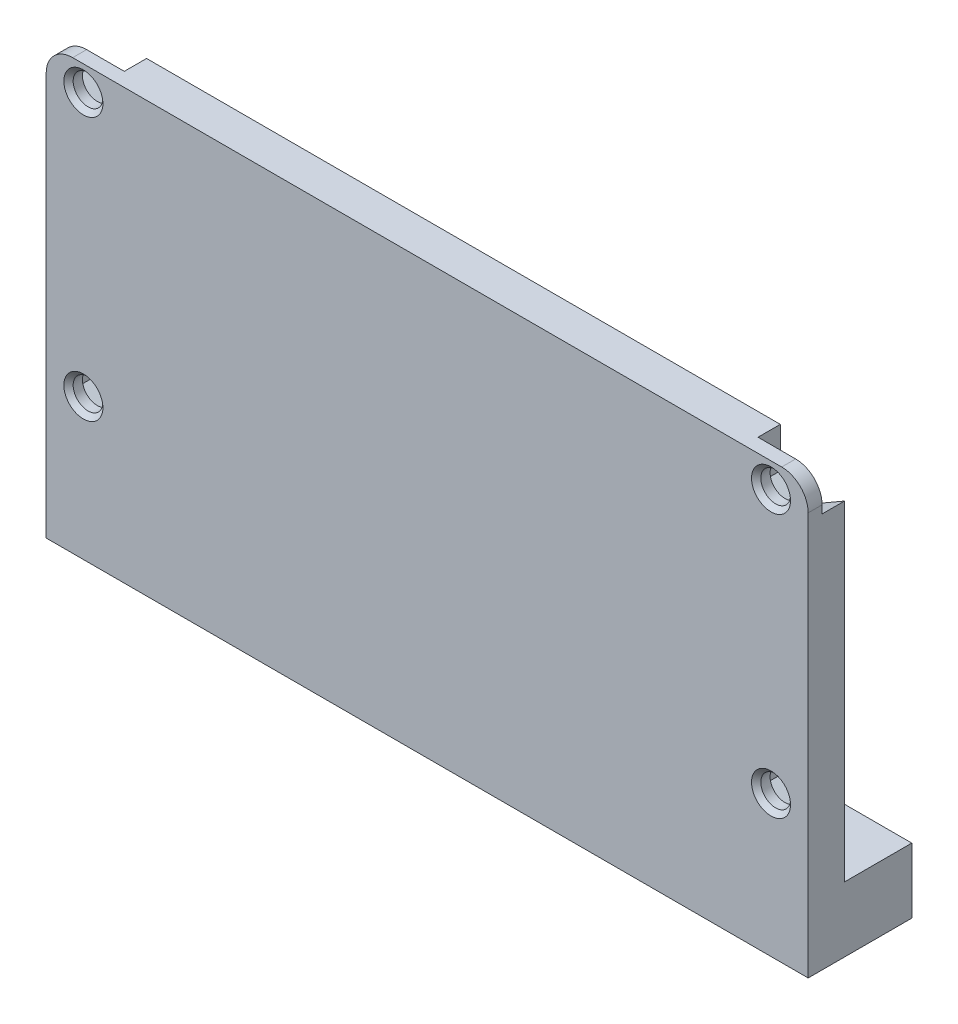
from build123d import *

# Parameters (mm, degrees)
SKETCH1_R                = 1.6
BOSS_EXTRUDE1_DEPTH      = 11.15
SKETCH2_W                = 82
SKETCH2_H                = 0.6
CUT_EXTRUDE1_DEPTH       = 8
CUT_EXTRUDE2_DEPTH       = 46.2
CUT_EXTRUDE3_DEPTH       = 40.2
CUT_EXTRUDE5_DEPTH       = 39.2
BOSS_EXTRUDE2_DEPTH      = 32.2
CHAMFER3_SIZE            = 1.1
CHAMFER4_SIZE            = 1.1
CUT_EXTRUDE12_DEPTH      = 1
CUT_EXTRUDE12_DEPTH_BACK = 83
FILLET3_R                = 15
SKETCH14_R               = 1.6
CUT_EXTRUDE14_DEPTH      = 12.1500001
BOSS_EXTRUDE3_DEPTH      = 3.5
SKETCH8_W                = 82
SKETCH8_H                = 0.6
CUT_EXTRUDE16_DEPTH      = 4.15
CUT_EXTRUDE17_DEPTH      = 2.4
CHAMFER5_SIZE            = 0.5


with BuildPart() as part:
    # Sketch1 → Boss-Extrude1 (new body)
    with BuildSketch(Plane.XY):
        with BuildLine():
            Line((0, -35.2), (82, -35.2))
            Line((82, -35.2), (82, 8.75))
            ThreePointArc((82, 8.75), (81.165254326, 10.765254326), (79.15, 11.6))
            Line((79.15, 11.6), (2.85, 11.6))
            ThreePointArc((2.85, 11.6), (0.834745674, 10.765254326), (0, 8.75))
            Line((0, 8.75), (0, -35.2))
        make_face()
        with Locations((4, 8.939640599)):
            Circle(SKETCH1_R, mode=Mode.SUBTRACT)
        with Locations((78, 8.939640599)):
            Circle(SKETCH1_R, mode=Mode.SUBTRACT)
    extrude(amount=BOSS_EXTRUDE1_DEPTH)

    # Sketch2 → Cut-Extrude1 (cut)
    with BuildSketch(Plane(origin=(0, 0, 0), x_dir=(-1, 0, 0), z_dir=(0, 0, -1))):
        with Locations((-41, -34.9)):
            Rectangle(SKETCH2_W, SKETCH2_H)
    cut_extrude1 = extrude(amount=-CUT_EXTRUDE1_DEPTH, mode=Mode.SUBTRACT)

    # Sketch3 → Cut-Extrude2 (cut)
    with BuildSketch(Plane.XZ.offset(34.6)):
        with BuildLine():
            Line((25.85, 4), (25.85, 0))
            Line((25.85, 0), (29.15, 0))
            Line((29.15, 0), (29.15, 4))
            ThreePointArc((29.15, 4), (27.5, 5.65), (25.85, 4))
        make_face()
        with BuildLine():
            ThreePointArc((14.15, 4), (12.5, 5.65), (10.85, 4))
            Line((10.85, 4), (10.85, 0))
            Line((10.85, 0), (14.15, 0))
            Line((14.15, 0), (14.15, 4))
        make_face()
        with BuildLine():
            ThreePointArc((23.25, 4), (20, 7.25), (16.75, 4))
            Line((16.75, 4), (16.75, 0))
            Line((16.75, 0), (23.25, 0))
            Line((23.25, 0), (23.25, 4))
        make_face()
    cut_extrude2 = extrude(amount=-CUT_EXTRUDE2_DEPTH, mode=Mode.SUBTRACT)

    # Sketch4 → Cut-Extrude3 (cut)
    with BuildSketch(Plane(origin=(0, 11.6, 0), x_dir=(1, 0, 0), z_dir=(0, 1, 0))):
        with BuildLine():
            Line((9.25, -4), (9.25, 0))
            Line((9.25, 0), (15.75, 0))
            Line((15.75, 0), (15.75, -4))
            ThreePointArc((15.75, -4), (12.5, -7.25), (9.25, -4))
        make_face()
        with BuildLine():
            Line((24.25, -4), (24.25, 0))
            Line((24.25, 0), (30.75, 0))
            Line((30.75, 0), (30.75, -4))
            ThreePointArc((30.75, -4), (27.5, -7.25), (24.25, -4))
        make_face()
    cut_extrude3 = extrude(amount=-CUT_EXTRUDE3_DEPTH, mode=Mode.SUBTRACT)

    # Sketch6 → Cut-Extrude5 (cut)
    with BuildSketch(Plane(origin=(0, 11.6, 0), x_dir=(1, 0, 0), z_dir=(0, 1, 0))):
        with BuildLine():
            Line((15.75, -4), (15.75, 0))
            Line((15.75, 0), (15.75, 0.65176216))
            Line((15.75, 0.65176216), (0, 0.65176216))
            Line((0, 0.65176216), (0, -7.25))
            Line((0, -7.25), (12.5, -7.25))
            ThreePointArc((12.5, -7.25), (14.798097039, -6.298097039), (15.75, -4))
        make_face()
        with BuildLine():
            Line((24.25, 0), (24.25, -4))
            ThreePointArc((24.25, -4), (25.201902961, -6.298097039), (27.5, -7.25))
            Line((27.5, -7.25), (41, -7.25))
            Line((41, -7.25), (41, 0))
            Line((41, 0), (24.25, 0))
        make_face()
    cut_extrude5 = extrude(amount=-CUT_EXTRUDE5_DEPTH, mode=Mode.SUBTRACT)

    # Mirror1: Cut-Extrude1, Cut-Extrude2, Cut-Extrude3, Cut-Extrude5 across plane
    add(cut_extrude1.mirror(Plane.ZY.offset(-41)), mode=Mode.SUBTRACT)
    add(cut_extrude2.mirror(Plane.ZY.offset(-41)), mode=Mode.SUBTRACT)
    add(cut_extrude3.mirror(Plane.ZY.offset(-41)), mode=Mode.SUBTRACT)
    add(cut_extrude5.mirror(Plane.ZY.offset(-41)), mode=Mode.SUBTRACT)

    # Sketch12 → Boss-Extrude2 (add)
    with BuildSketch(Plane(origin=(0, 11.6, 0), x_dir=(1, 0, 0), z_dir=(0, 1, 0))):
        with BuildLine():
            Line((16.75, -4), (16.75, 0))
            Line((16.75, 0), (18, 0))
            Line((18, 0), (18.11, -3.084631222))
            ThreePointArc((18.11, -3.084631222), (20, -6.1), (21.89, -3.084631222))
            Line((21.89, -3.084631222), (22, 0))
            Line((22, 0), (23.25, 0))
            Line((23.25, 0), (23.25, -4))
            ThreePointArc((23.25, -4), (20, -7.25), (16.75, -4))
        make_face()
        with BuildLine():
            Line((58.75, -4), (58.75, 0))
            Line((58.75, 0), (60.05, 0))
            Line((60.05, 0), (60.155, -3.106425717))
            ThreePointArc((60.155, -3.106425717), (62, -6.05), (63.845, -3.106425717))
            Line((63.845, -3.106425717), (63.95, 0))
            Line((63.95, 0), (65.25, 0))
            Line((65.25, 0), (65.25, -4))
            ThreePointArc((65.25, -4), (62, -7.25), (58.75, -4))
        make_face()
    extrude(amount=-BOSS_EXTRUDE2_DEPTH)

    # Chamfer3
    chamfer3_edges = [part.edges().sort_by_distance(p)[0] for p in [
        (65.25, -20.6, 2),
        (58.75, -20.6, 2),
        (62, -20.6, 7.25),
    ]]
    chamfer(chamfer3_edges, length=CHAMFER3_SIZE)

    # Chamfer4
    chamfer4_edges = [part.edges().sort_by_distance(p)[0] for p in [
        (23.25, -20.6, 2),
        (16.75, -20.6, 2),
        (20, -20.6, 7.25),
    ]]
    chamfer(chamfer4_edges, length=CHAMFER4_SIZE)

    # Sketch9 → Cut-Extrude12 (cut, two sides)
    with BuildSketch(Plane.ZY) as cut_extrude12_sk:
        Polygon((-106.219800457, 11.6), (0, 11.6), (7.25, 11.6), (0, 2.4), (-65.744961499, -81.028089075), (-260.411588221, -166.089763625), (-300.886427179, -73.46167455), align=None)
    extrude(amount=CUT_EXTRUDE12_DEPTH, mode=Mode.SUBTRACT)
    extrude(cut_extrude12_sk.sketch, amount=-CUT_EXTRUDE12_DEPTH_BACK, mode=Mode.SUBTRACT)

    # Fillet3
    fillet3_edges = [part.edges().sort_by_distance(p)[0] for p in [
        (16.875, 2.4, 0),
        (23.125, 2.4, 0),
        (58.9, 2.4, 0),
        (65.1, 2.4, 0),
    ]]
    fillet(fillet3_edges, radius=FILLET3_R)

    # Sketch14 → Cut-Extrude14 (cut, through all)
    with BuildSketch(Plane.XY.offset(11.15)):
        with Locations((4, -19.400359401)):
            Circle(SKETCH14_R)
    cut_extrude14 = extrude(amount=-CUT_EXTRUDE14_DEPTH, mode=Mode.SUBTRACT)

    # Mirror3: Cut-Extrude14 across plane
    add(cut_extrude14.mirror(Plane.ZY.offset(-41)), mode=Mode.SUBTRACT)

    # Sketch18 → Boss-Extrude3 (add)
    with BuildSketch(Plane(origin=(0, -27.6, 0), x_dir=(1, 0, 0), z_dir=(0, 1, 0))):
        with BuildLine():
            Line((14.15, 0), (14.15, -1.2))
            ThreePointArc((14.15, -1.2), (15.321790212, -2.38754845), (15.75, -4))
            Line((15.75, -4), (15.75, 0))
            Line((15.75, 0), (14.15, 0))
        make_face()
        with BuildLine():
            Line((10.85, -1.2), (10.85, 0))
            Line((10.85, 0), (9.25, 0))
            Line((9.25, 0), (9.25, -4))
            ThreePointArc((9.25, -4), (9.678209788, -2.38754845), (10.85, -1.2))
        make_face()
        with BuildLine():
            Line((29.15, 0), (29.15, -1.2))
            ThreePointArc((29.15, -1.2), (30.321790212, -2.38754845), (30.75, -4))
            Line((30.75, -4), (30.75, 0))
            Line((30.75, 0), (29.15, 0))
        make_face()
        with BuildLine():
            Line((25.85, -1.2), (25.85, 0))
            Line((25.85, 0), (24.25, 0))
            Line((24.25, 0), (24.25, -4))
            ThreePointArc((24.25, -4), (24.678209788, -2.38754845), (25.85, -1.2))
        make_face()
    boss_extrude3 = extrude(amount=-BOSS_EXTRUDE3_DEPTH)

    # Mirror5: Boss-Extrude3 across plane
    add(boss_extrude3.mirror(Plane.ZY.offset(-41)))

    # Sketch8 → Cut-Extrude16 (cut, through all)
    with BuildSketch(Plane(origin=(0, 0, 8), x_dir=(-1, 0, 0), z_dir=(0, 0, -1))):
        with Locations((-41, -34.9)):
            Rectangle(SKETCH8_W, SKETCH8_H)
    extrude(amount=-CUT_EXTRUDE16_DEPTH, mode=Mode.SUBTRACT)

    # Sketch20 → Cut-Extrude17 (cut)
    with BuildSketch(Plane(origin=(0, 0, 7.25), x_dir=(-1, 0, 0), z_dir=(0, 0, -1))):
        Polygon((-80.9, 12.288272161), (-75.1, 12.288272161), (-75.1, 7.265324819), (-78, 5.591009038), (-84.071495483, 9.096388589), align=None)
        Polygon((-75.1, -21.074675181), (-75.1, -17.72604362), (-78, -16.051727839), (-80.9, -17.72604362), (-80.9, -21.074675181), (-78, -22.748990962), align=None)
    cut_extrude17 = extrude(amount=-CUT_EXTRUDE17_DEPTH, mode=Mode.SUBTRACT)

    # Mirror7: Cut-Extrude17 across plane
    add(cut_extrude17.mirror(Plane.ZY.offset(-41)), mode=Mode.SUBTRACT)

    # Chamfer5
    chamfer5_edges = [part.edges().sort_by_distance(p)[0] for p in [
        (2.4, 8.939640599, 11.15),
        (76.4, 8.939640599, 11.15),
        (2.4, -19.400359401, 11.15),
        (79.6, -19.400359401, 11.15),
    ]]
    chamfer(chamfer5_edges, length=CHAMFER5_SIZE)


solid = part.part
